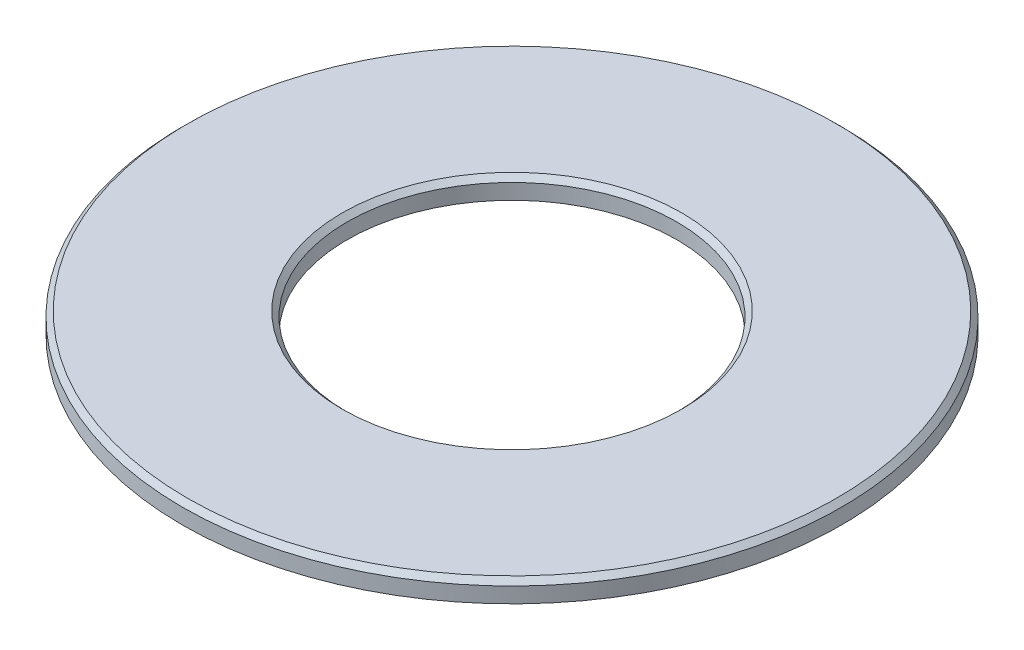
from build123d import *

# Parameters (mm, degrees)
SKIZZE1_W  = 1.6
SKIZZE1_H  = 0.2
FASE1_SIZE = 0.05


with BuildPart() as part:
    # Skizze1 → Rotation1 (revolve)
    with BuildSketch(Plane.XY):
        with Locations((2.4, 0.1)):
            Rectangle(SKIZZE1_W, SKIZZE1_H)
    revolve(axis=Axis((0, 0, 0), (0, 1, 0)))

    # Fase1
    fase1_edges = [part.edges().sort_by_distance(p)[0] for p in [
        (-3.2, 0.2, 0),
        (-1.6, 0.2, 0),
    ]]
    chamfer(fase1_edges, length=FASE1_SIZE)


solid = part.part
